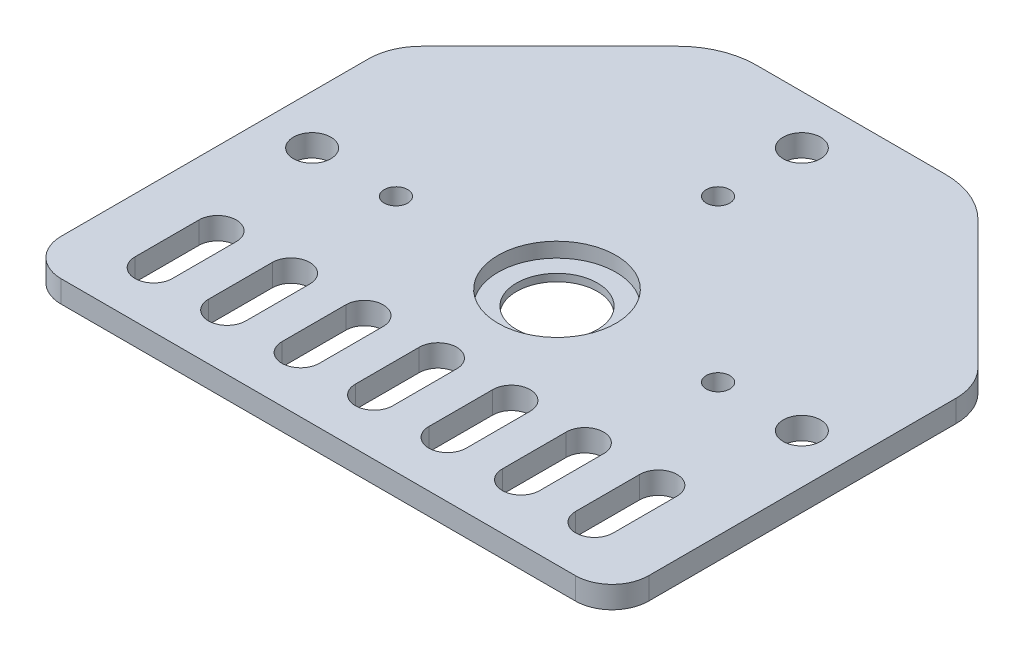
from build123d import *

# Parameters (mm, degrees)
SKETCH1_R           = 1.6
SKETCH1_R_2         = 5.5
SKETCH1_R_3         = 2.55
BOSS_EXTRUDE1_DEPTH = 3
SKETCH2_R           = 8.025
CUT_EXTRUDE1_DEPTH  = 2


with BuildPart() as part:
    # Sketch1 → Boss-Extrude1 (new body)
    with BuildSketch(Plane(origin=(0, 0, 0), x_dir=(1, 0, 0), z_dir=(0, 1, 0))):
        with BuildLine():
            Line((35, -32.5), (-35, -32.5))
            ThreePointArc((-35, -32.5), (-38.535533906, -31.035533906), (-40, -27.5))
            Line((-40, -27.5), (-40, 14.306951673))
            ThreePointArc((-40, 14.306951673), (-39.448126611, 17.081406557), (-37.876524164, 19.433475836))
            Line((-37.876524164, 19.433475836), (-20.438099577, 36.871900423))
            ThreePointArc((-20.438099577, 36.871900423), (-16.973258212, 39.187033407), (-12.886199154, 40))
            Line((-12.886199154, 40), (12.886199154, 40))
            ThreePointArc((12.886199154, 40), (16.973258212, 39.187033407), (20.438099577, 36.871900423))
            Line((20.438099577, 36.871900423), (37.876524164, 19.433475836))
            ThreePointArc((37.876524164, 19.433475836), (39.448126611, 17.081406557), (40, 14.306951673))
            Line((40, 14.306951673), (40, -27.5))
            ThreePointArc((40, -27.5), (38.535533906, -31.035533906), (35, -32.5))
        make_face()
        with Locations((21.920310217, 0)):
            Circle(SKETCH1_R, mode=Mode.SUBTRACT)
        with Locations((-21.920310217, 0)):
            Circle(SKETCH1_R, mode=Mode.SUBTRACT)
        Circle(SKETCH1_R_2, mode=Mode.SUBTRACT)
        with Locations((0, 21.920310217)):
            Circle(SKETCH1_R, mode=Mode.SUBTRACT)
        with Locations((-33.333013665, 0)):
            Circle(SKETCH1_R_3, mode=Mode.SUBTRACT)
        with Locations((0, 33.333013665)):
            Circle(SKETCH1_R_3, mode=Mode.SUBTRACT)
        with Locations((33.333013665, 0)):
            Circle(SKETCH1_R_3, mode=Mode.SUBTRACT)
        with BuildLine():
            Line((27.45, -24.9), (27.45, -16.2))
            ThreePointArc((27.45, -16.2), (30, -13.65), (32.55, -16.2))
            Line((32.55, -16.2), (32.55, -24.9))
            ThreePointArc((32.55, -24.9), (30, -27.45), (27.45, -24.9))
        make_face(mode=Mode.SUBTRACT)
        with BuildLine():
            Line((17.45, -24.9), (17.45, -16.2))
            ThreePointArc((17.45, -16.2), (20, -13.65), (22.55, -16.2))
            Line((22.55, -16.2), (22.55, -24.9))
            ThreePointArc((22.55, -24.9), (20, -27.45), (17.45, -24.9))
        make_face(mode=Mode.SUBTRACT)
        with BuildLine():
            Line((7.45, -24.9), (7.45, -16.2))
            ThreePointArc((7.45, -16.2), (10, -13.65), (12.55, -16.2))
            Line((12.55, -16.2), (12.55, -24.9))
            ThreePointArc((12.55, -24.9), (10, -27.45), (7.45, -24.9))
        make_face(mode=Mode.SUBTRACT)
        with BuildLine():
            Line((-2.55, -24.9), (-2.55, -16.2))
            ThreePointArc((-2.55, -16.2), (0, -13.65), (2.55, -16.2))
            Line((2.55, -16.2), (2.55, -24.9))
            ThreePointArc((2.55, -24.9), (0, -27.45), (-2.55, -24.9))
        make_face(mode=Mode.SUBTRACT)
        with BuildLine():
            Line((-12.55, -24.9), (-12.55, -16.2))
            ThreePointArc((-12.55, -16.2), (-10, -13.65), (-7.45, -16.2))
            Line((-7.45, -16.2), (-7.45, -24.9))
            ThreePointArc((-7.45, -24.9), (-10, -27.45), (-12.55, -24.9))
        make_face(mode=Mode.SUBTRACT)
        with BuildLine():
            Line((-22.55, -24.9), (-22.55, -16.2))
            ThreePointArc((-22.55, -16.2), (-20, -13.65), (-17.45, -16.2))
            Line((-17.45, -16.2), (-17.45, -24.9))
            ThreePointArc((-17.45, -24.9), (-20, -27.45), (-22.55, -24.9))
        make_face(mode=Mode.SUBTRACT)
        with BuildLine():
            Line((-32.55, -24.9), (-32.55, -16.2))
            ThreePointArc((-32.55, -16.2), (-30, -13.65), (-27.45, -16.2))
            Line((-27.45, -16.2), (-27.45, -24.9))
            ThreePointArc((-27.45, -24.9), (-30, -27.45), (-32.55, -24.9))
        make_face(mode=Mode.SUBTRACT)
    extrude(amount=BOSS_EXTRUDE1_DEPTH)

    # Sketch2 → Cut-Extrude1 (cut)
    with BuildSketch(Plane(origin=(0, 3, 0), x_dir=(1, 0, 0), z_dir=(0, 1, 0))):
        Circle(SKETCH2_R)
    extrude(amount=-CUT_EXTRUDE1_DEPTH, mode=Mode.SUBTRACT)


solid = part.part
